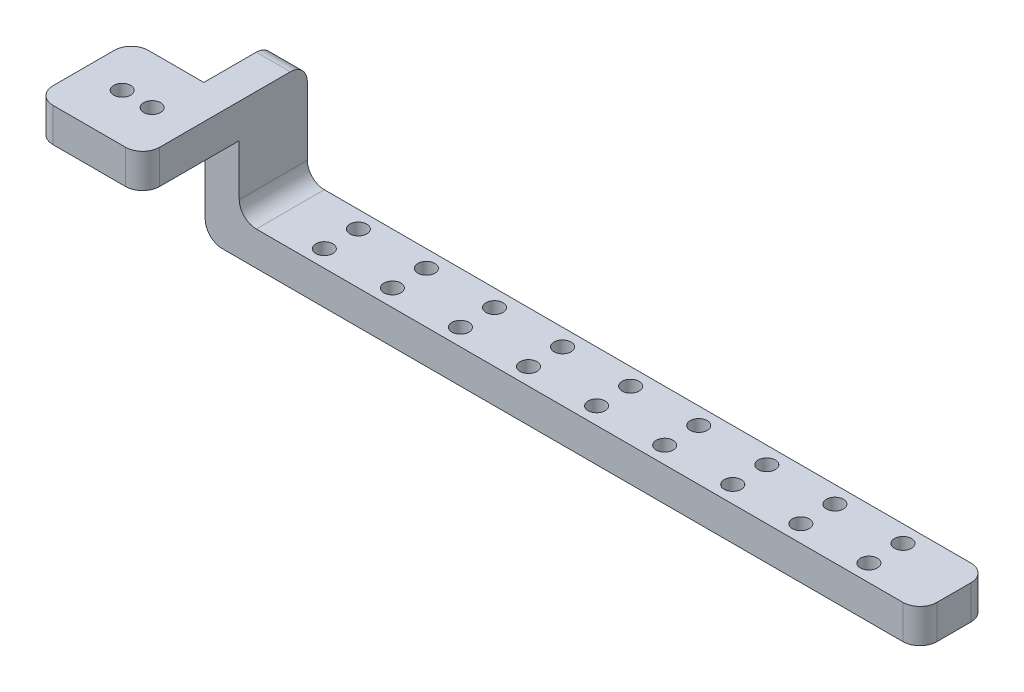
from build123d import *

# Parameters (mm, degrees)
SKETCH1_W           = 41.4782
SKETCH1_H           = 17.78
SKETCH1_R           = 4.445
SKETCH1_R_2         = 1.5875
BOSS_EXTRUDE1_DEPTH = 6.35
SKETCH2_W           = 6.35
SKETCH2_H           = 6.35
BOSS_EXTRUDE2_DEPTH = 0.254
SKETCH3_W           = 6.35
SKETCH3_H           = 25.4
BOSS_EXTRUDE3_DEPTH = 12.7
SKETCH4_W           = 12.7
SKETCH4_H           = 6.35
BOSS_EXTRUDE4_DEPTH = 127
SKETCH5_R           = 1.5875
CUT_EXTRUDE1_DEPTH  = 7.35
SKETCH6_W           = 21.59
SKETCH6_H           = 17.78
CUT_EXTRUDE2_DEPTH  = 26.4
FILLET1_R           = 3.175


with BuildPart() as part:
    # Sketch1 → Boss-Extrude1 (new body)
    with BuildSketch(Plane(origin=(0, 0, 0), x_dir=(1, 0, 0), z_dir=(0, 1, 0))):
        Rectangle(SKETCH1_W, SKETCH1_H)
        with Locations((-8.0391, 0)):
            Circle(SKETCH1_R, mode=Mode.SUBTRACT)
        with Locations((13.6271, 0)):
            Circle(SKETCH1_R_2, mode=Mode.SUBTRACT)
        with Locations((8.0391, 0)):
            Circle(SKETCH1_R_2, mode=Mode.SUBTRACT)
    extrude(amount=BOSS_EXTRUDE1_DEPTH)

    # Sketch2 → Boss-Extrude2 (add)
    with BuildSketch(Plane(origin=(0, 0, -8.89), x_dir=(-1, 0, 0), z_dir=(0, 0, -1))):
        with Locations((-17.5641, 3.175)):
            Rectangle(SKETCH2_W, SKETCH2_H)
    extrude(amount=BOSS_EXTRUDE2_DEPTH)

    # Sketch3 → Boss-Extrude3 (add)
    with BuildSketch(Plane(origin=(0, 0, -9.144), x_dir=(-1, 0, 0), z_dir=(0, 0, -1))):
        with Locations((-17.5641, -6.35)):
            Rectangle(SKETCH3_W, SKETCH3_H)
    extrude(amount=BOSS_EXTRUDE3_DEPTH)

    # Sketch4 → Boss-Extrude4 (add)
    with BuildSketch(Plane(origin=(20.7391, 0, 0), x_dir=(0, 0, -1), z_dir=(1, 0, 0))):
        with Locations((15.494, -15.875)):
            Rectangle(SKETCH4_W, SKETCH4_H)
    extrude(amount=BOSS_EXTRUDE4_DEPTH)

    # Sketch5 → Cut-Extrude1 (cut, through all)
    with BuildSketch(Plane(origin=(0, -12.7, 0), x_dir=(1, 0, 0), z_dir=(0, 1, 0))):
        with Locations((33.4391, 18.669)):
            Circle(SKETCH5_R)
        with Locations((33.4391, 12.319)):
            Circle(SKETCH5_R)
        with Locations((46.1391, 12.319)):
            Circle(SKETCH5_R)
        with Locations((46.1391, 18.669)):
            Circle(SKETCH5_R)
        with Locations((58.8391, 12.319)):
            Circle(SKETCH5_R)
        with Locations((58.8391, 18.669)):
            Circle(SKETCH5_R)
        with Locations((71.5391, 12.319)):
            Circle(SKETCH5_R)
        with Locations((71.5391, 18.669)):
            Circle(SKETCH5_R)
        with Locations((84.2391, 12.319)):
            Circle(SKETCH5_R)
        with Locations((84.2391, 18.669)):
            Circle(SKETCH5_R)
        with Locations((96.9391, 12.319)):
            Circle(SKETCH5_R)
        with Locations((96.9391, 18.669)):
            Circle(SKETCH5_R)
        with Locations((109.6391, 12.319)):
            Circle(SKETCH5_R)
        with Locations((109.6391, 18.669)):
            Circle(SKETCH5_R)
        with Locations((122.3391, 12.319)):
            Circle(SKETCH5_R)
        with Locations((122.3391, 18.669)):
            Circle(SKETCH5_R)
        with Locations((135.0391, 12.319)):
            Circle(SKETCH5_R)
        with Locations((135.0391, 18.669)):
            Circle(SKETCH5_R)
    extrude(amount=-CUT_EXTRUDE1_DEPTH, mode=Mode.SUBTRACT)

    # Sketch6 → Cut-Extrude2 (cut, through all)
    with BuildSketch(Plane(origin=(0, 6.35, 0), x_dir=(1, 0, 0), z_dir=(0, 1, 0))):
        with Locations((-9.9441, 0)):
            Rectangle(SKETCH6_W, SKETCH6_H)
    extrude(amount=-CUT_EXTRUDE2_DEPTH, mode=Mode.SUBTRACT)

    # Fillet1
    fillet1_edges = [part.edges().sort_by_distance(p)[0] for p in [
        (0.8509, 3.175, 8.89),
        (0.8509, 3.175, -8.89),
        (14.3891, -19.05, -15.494),
        (17.5641, 6.35, -21.844),
        (20.7391, -12.7, -15.494),
        (147.7391, -15.875, -9.144),
        (147.7391, -15.875, -21.844),
        (20.7391, 3.175, 8.89),
    ]]
    fillet(fillet1_edges, radius=FILLET1_R)


solid = part.part
